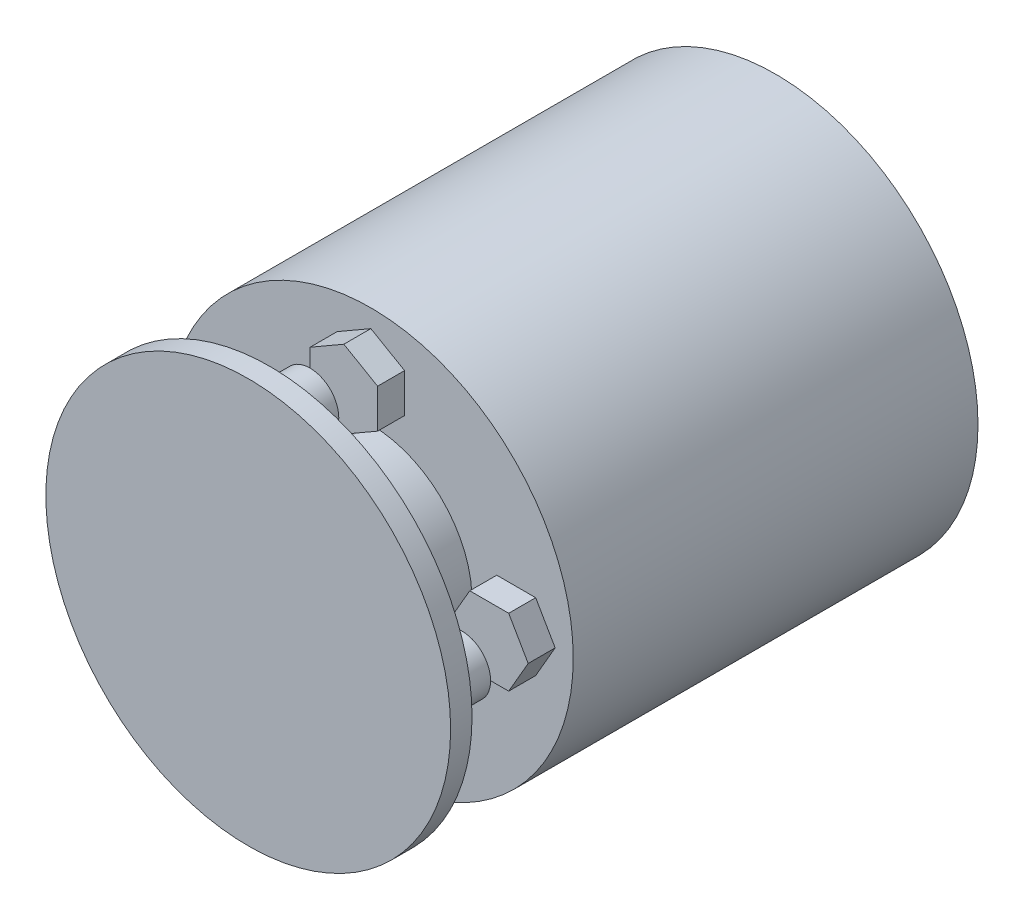
from build123d import *

# Parameters (mm, degrees)
BOSS_EXTRUDE1_DEPTH     = 4
SKETCH4_R               = 4.25
BOSS_EXTRUDE2_DEPTH     = 6
SKETCH5_R               = 15
BOSS_EXTRUDE3_DEPTH     = 15
CUT_EXTRUDE1_DEPTH      = 2
CUT_EXTRUDE1_DEPTH_BACK = 91.373284908
SKETCH10_W              = 4
SKETCH10_H              = 4
BOSS_EXTRUDE4_DEPTH     = 3
SKETCH11_W              = 4
SKETCH11_H              = 4
CUT_EXTRUDE2_DEPTH      = 3


with BuildPart() as part:
    # Sketch2 → Revolve1 (revolve)
    with BuildSketch(Plane(origin=(0, 0, 0), x_dir=(0, 0, -1), z_dir=(1, 0, 0)), mode=Mode.PRIVATE) as revolve1_sk:
        Polygon((0, 0), (0, 30), (-60, 30), (-60, 6), (-75, 6), (-75, 30), (-78.175, 30), (-78.175, 0), align=None)
    revolve(revolve1_sk.sketch.rotate(Axis((0, 0, 1885.789937519), (0, 0, -1)), 90), axis=Axis((0, 0, 1885.789937519), (0, 0, -1)))

    # Sketch3 → Boss-Extrude1 (add)
    with BuildSketch(Plane.XY.offset(60)):
        Polygon((15.774497248, 0), (18.661248594, -5), (24.434751286, -5), (27.321502632, 0), (24.434751286, 5), (18.661248594, 5), align=None)
        Polygon((0, 15.774497248), (5, 18.661248594), (5, 24.434751286), (0, 27.321502632), (-5, 24.434751286), (-5, 18.661248594), align=None)
        Polygon((0, -15.774497248), (-5, -18.661248594), (-5, -24.434751286), (0, -27.321502632), (5, -24.434751286), (5, -18.661248594), align=None)
        Polygon((-15.774497248, 0), (-18.661248594, 5), (-24.434751286, 5), (-27.321502632, 0), (-24.434751286, -5), (-18.661248594, -5), align=None)
    extrude(amount=BOSS_EXTRUDE1_DEPTH)

    # Sketch4 → Boss-Extrude2 (add)
    with BuildSketch(Plane(origin=(0, 0, 75), x_dir=(-1, 0, 0), z_dir=(0, 0, -1))):
        with Locations(Location((0, 22.5, 0), (0, 0, 180))):
            Circle(SKETCH4_R)
        with Locations(Location((22.5, 0, 0), (0, 0, 180))):
            Circle(SKETCH4_R)
        with Locations(Location((0, -22.5, 0), (0, 0, 180))):
            Circle(SKETCH4_R)
        with Locations(Location((-22.5, 0, 0), (0, 0, 180))):
            Circle(SKETCH4_R)
    extrude(amount=BOSS_EXTRUDE2_DEPTH)


with BuildPart() as body_2:
    # Sketch5 → Boss-Extrude3 (new body)
    with BuildSketch(Plane.XY.offset(60)):
        Circle(SKETCH5_R)
        with BuildLine():
            Line((-2, 5.656854249), (-2, 8))
            Line((-2, 8), (2, 8))
            Line((2, 8), (2, 5.656854249))
            ThreePointArc((2, 5.656854249), (0, -6), (-2, 5.656854249))
        make_face(mode=Mode.SUBTRACT)
    extrude(amount=BOSS_EXTRUDE3_DEPTH)

    # Sketch7 → Cut-Revolve3 (revolve, cut)
    with BuildSketch(Plane.XY.offset(67.5), mode=Mode.PRIVATE) as cut_revolve3_sk:
        Polygon((12.842799539, -10.5), (12.842799539, -7.75), (2, -7.75), (2, -9), (-4, -9), (-4, -10.5), align=None)
    revolve(cut_revolve3_sk.sketch.rotate(Axis((-1000, -10.5, 67.5), (1, 0, 0)), 90), axis=Axis((-1000, -10.5, 67.5), (1, 0, 0)), mode=Mode.SUBTRACT)

    # Sketch9 → Cut-Extrude1 (cut, two sides)
    with BuildSketch(Plane(origin=(-4, 0, 0), x_dir=(0, 0, -1), z_dir=(1, 0, 0))) as cut_extrude1_sk:
        Polygon((-65.91228676, -13.25), (-64.324573519, -10.5), (-65.91228676, -7.75), (-69.08771324, -7.75), (-70.675426481, -10.5), (-69.08771324, -13.25), align=None)
    extrude(amount=CUT_EXTRUDE1_DEPTH, mode=Mode.SUBTRACT)
    extrude(cut_extrude1_sk.sketch, amount=-CUT_EXTRUDE1_DEPTH_BACK, mode=Mode.SUBTRACT)


with BuildPart() as body_3:
    # Split1: the piece on the far side of the plane
    add(body_2.part)
    split(bisect_by=Plane(origin=(0, 0, 0), x_dir=(0, 0, 1), z_dir=(1, 0, 0)), keep=Keep.BOTTOM)

    # Sketch11 → Cut-Extrude2 (cut)
    with BuildSketch(Plane(origin=(0, 0, 0), x_dir=(0, 0, -1), z_dir=(1, 0, 0))):
        with Locations((-67.5, 11.5)):
            Rectangle(SKETCH11_W, SKETCH11_H)
    extrude(amount=-CUT_EXTRUDE2_DEPTH, mode=Mode.SUBTRACT)


with BuildPart() as body_2_1:
    add(body_2.part)

    # Split1
    split(bisect_by=Plane(origin=(0, 0, 0), x_dir=(0, 0, 1), z_dir=(1, 0, 0)), keep=Keep.TOP)

    # Sketch10 → Boss-Extrude4 (add)
    with BuildSketch(Plane.ZY):
        with Locations((67.5, 11.5)):
            Rectangle(SKETCH10_W, SKETCH10_H)
    extrude(amount=BOSS_EXTRUDE4_DEPTH)


solid = Compound([part.part, body_3.part, body_2_1.part])
